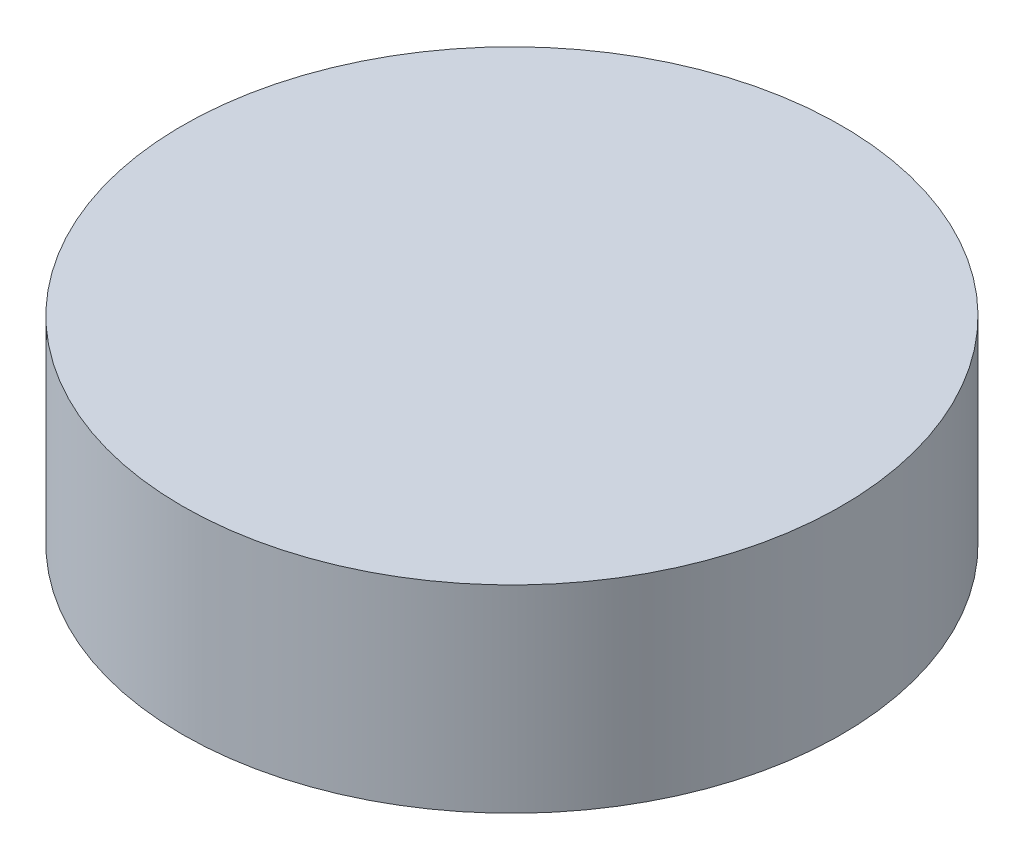
from build123d import *

# Parameters (mm, degrees)
SKETCH_1_R          = 2.5
EXTRUDE_1_DEPTH     = 2
SKETCH_2_R          = 2.5
EXTRUDE_2_DEPTH     = 0.5
SKETCH_3_R          = 2.5
CUT_EXTRUDE_1_DEPTH = 1


with BuildPart() as part:
    # ｽｹｯﾁ1 → ﾎﾞｽ - 押し出し1 (new body)
    with BuildSketch(Plane(origin=(0, 0, 0), x_dir=(1, 0, 0), z_dir=(0, 1, 0))):
        Circle(SKETCH_1_R)
    extrude(amount=EXTRUDE_1_DEPTH)

    # ｽｹｯﾁ2 → ﾎﾞｽ - 押し出し2 (add)
    with BuildSketch(Plane(origin=(0, 2, 0), x_dir=(1, 0, 0), z_dir=(0, 1, 0))):
        Circle(SKETCH_2_R)
    extrude(amount=EXTRUDE_2_DEPTH)

    # ｽｹｯﾁ3 → ｶｯﾄ - 押し出し1 (cut)
    with BuildSketch(Plane(origin=(0, 2.5, 0), x_dir=(1, 0, 0), z_dir=(0, 1, 0))):
        Circle(SKETCH_3_R)
    extrude(amount=-CUT_EXTRUDE_1_DEPTH, mode=Mode.SUBTRACT)


solid = part.part
